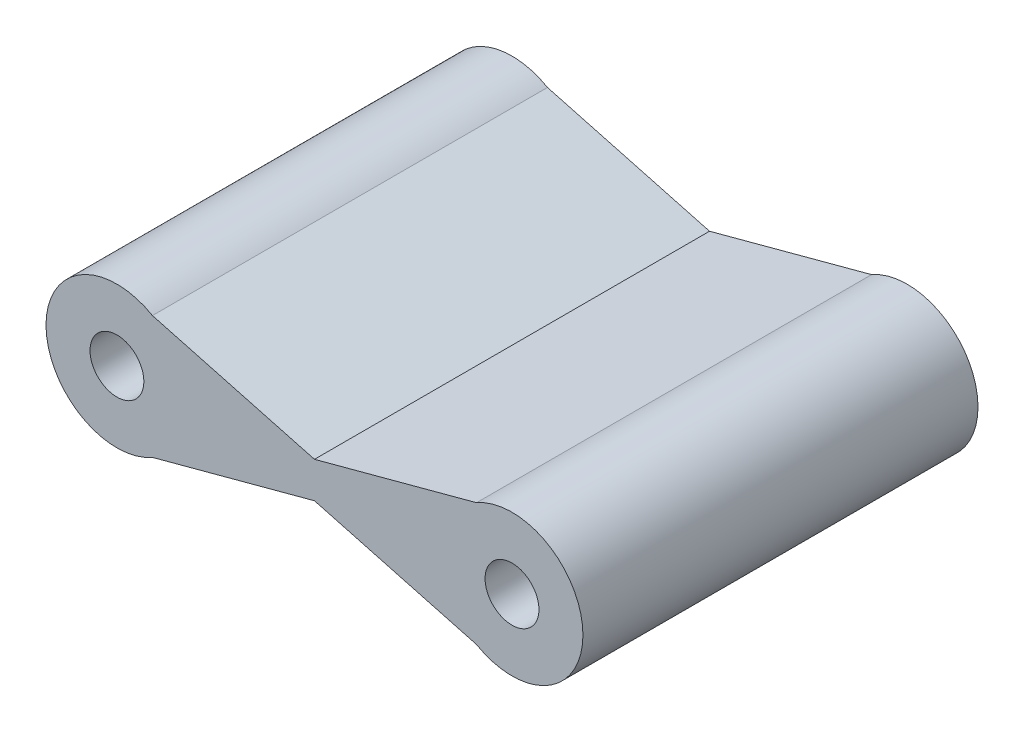
from build123d import *

# Parameters (mm, degrees)
SKETCH1_R           = 0.75
BOSS_EXTRUDE1_DEPTH = 11


with BuildPart() as part:
    # Sketch1 → Boss-Extrude1 (new body)
    with BuildSketch(Plane.XY):
        with BuildLine():
            Line((10.011757676, 2.209971377), (5.5, 1))
            Line((5.5, 1), (0.988242324, 2.209971377))
            ThreePointArc((0.988242324, 2.209971377), (-1.975, 0.5), (0.988242324, -1.209971377))
            Line((0.988242324, -1.209971377), (5.5, 0))
            Line((5.5, 0), (10.011757676, -1.209971377))
            ThreePointArc((10.011757676, -1.209971377), (12.975, 0.5), (10.011757676, 2.209971377))
        make_face()
        with Locations((0, 0.5)):
            Circle(SKETCH1_R, mode=Mode.SUBTRACT)
        with Locations((11, 0.5)):
            Circle(SKETCH1_R, mode=Mode.SUBTRACT)
    extrude(amount=BOSS_EXTRUDE1_DEPTH)


solid = part.part
